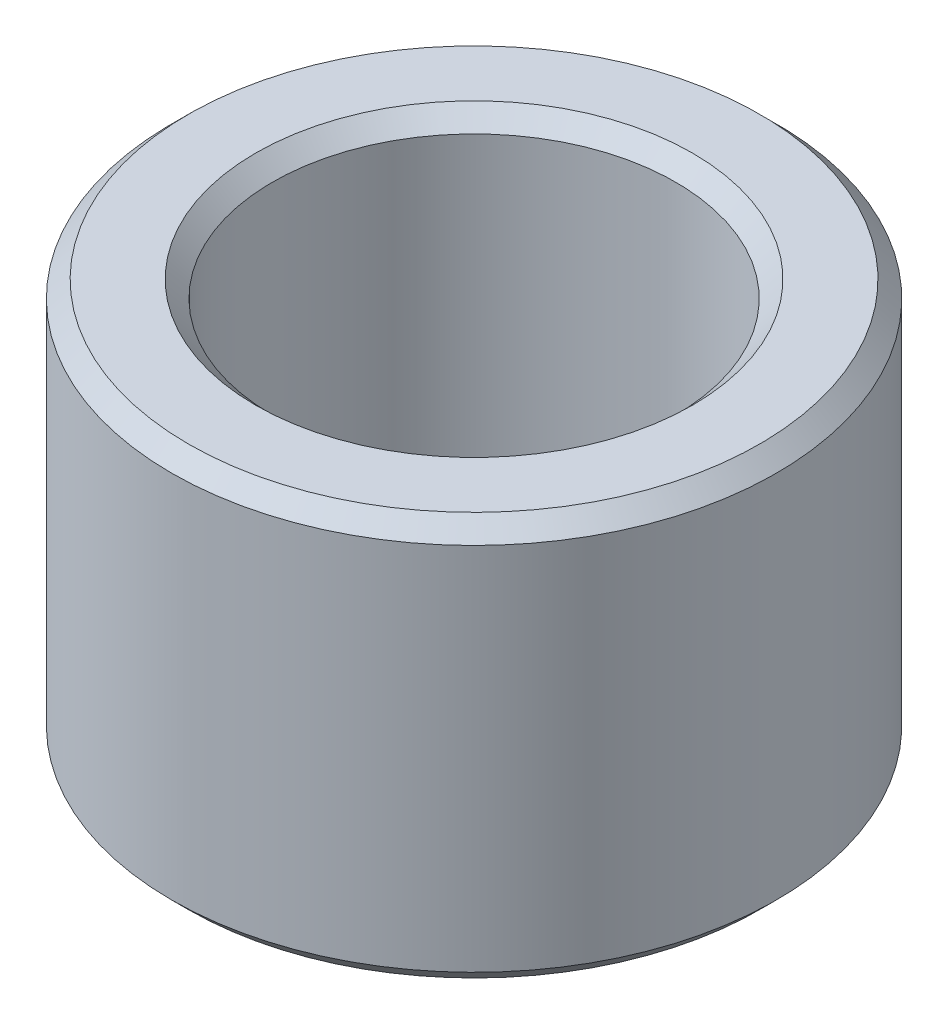
from build123d import *

# Parameters (mm, degrees)
ESQUISSE1_R        = 9
ESQUISSE1_R_2      = 6
BOSS_EXTRU_1_DEPTH = 12
CHANFREIN1_SIZE    = 0.5


with BuildPart() as part:
    # Esquisse1 → Boss.-Extru.1 (new body)
    with BuildSketch(Plane(origin=(0, 0, 0), x_dir=(1, 0, 0), z_dir=(0, 1, 0))):
        with Locations(Location((0, 0, 0), (0, 0, 270))):  # turned: the seam where the file's is
            Circle(ESQUISSE1_R)
        with Locations(Location((0, 0, 0), (0, 0, 270))):  # turned: the seam where the file's is
            Circle(ESQUISSE1_R_2, mode=Mode.SUBTRACT)
    extrude(amount=BOSS_EXTRU_1_DEPTH)

    # Chanfrein1
    chanfrein1_edges = [part.edges().sort_by_distance(p)[0] for p in [
        (0, 0, -9),
        (0, 12, -9),
        (0, 0, -6),
        (0, 12, -6),
    ]]
    chamfer(chanfrein1_edges, length=CHANFREIN1_SIZE)


solid = part.part
